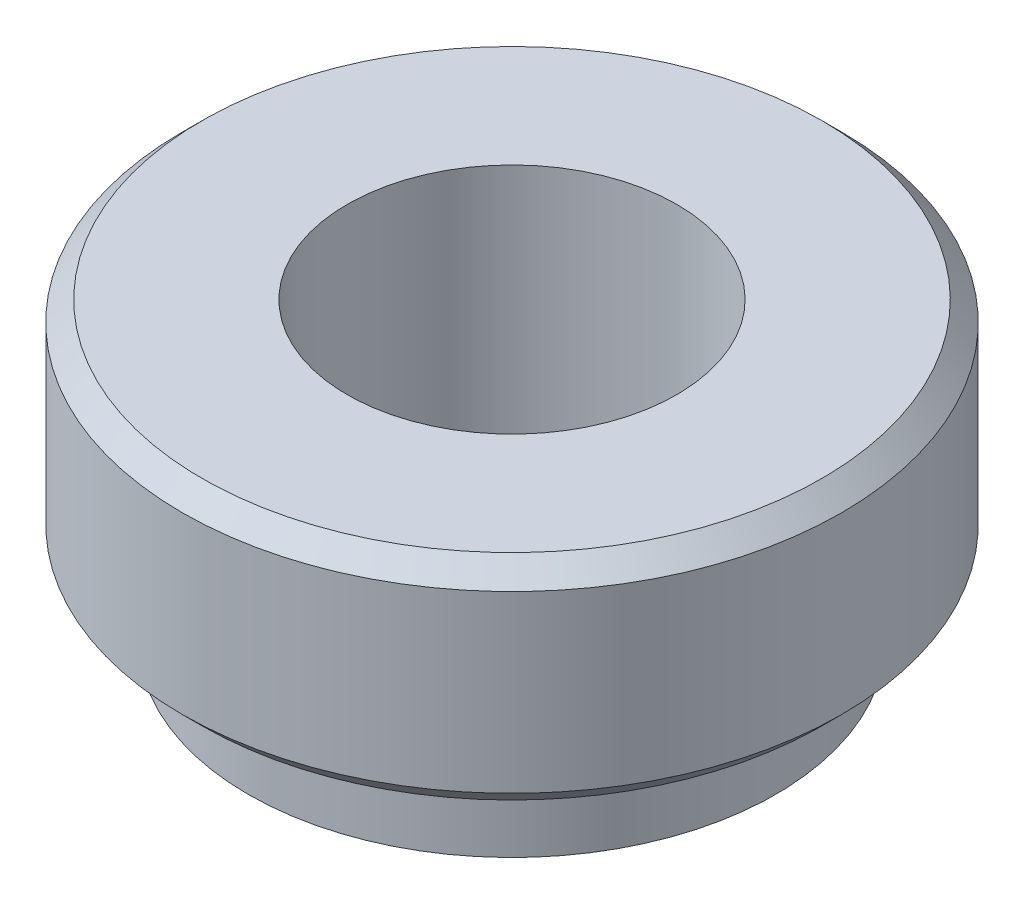
from build123d import *

# Parameters (mm, degrees)
CHANFREIN1_SIZE = 0.3


with BuildPart() as part:
    # Esquisse1 → Révolution1 (revolve)
    with BuildSketch(Plane.XY, mode=Mode.PRIVATE) as r_volution1_sk:
        Polygon((-2.5, 0), (-2.5, 4.5), (-5, 4.5), (-5, 1.25), (-4, 1.25), (-4, 0), align=None)
    revolve(r_volution1_sk.sketch.rotate(Axis((0, 0, 0), (0, 1, 0)), 270), axis=Axis((0, 0, 0), (0, 1, 0)))  # turned: the seam where the file's is

    # Chanfrein1
    chanfrein1_edges = [part.edges().sort_by_distance(p)[0] for p in [
        (0, 1.25, 5),
        (0, 4.5, 5),
    ]]
    chamfer(chanfrein1_edges, length=CHANFREIN1_SIZE)


solid = part.part
